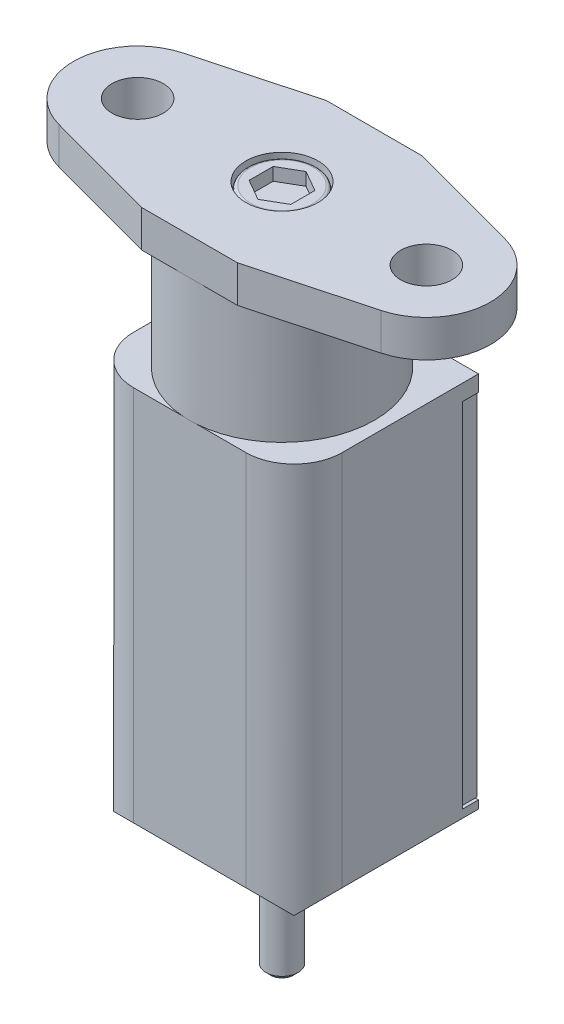
from build123d import *

# Parameters (mm, degrees)
SKETCH1_R                = 1.6
BOSS_EXTRUDE1_DEPTH      = 2.3
SKETCH2_R                = 5.765
BOSS_EXTRUDE2_DEPTH      = 7.7
SKETCH3_W                = 13
SKETCH3_H                = 26.5
BOSS_EXTRUDE3_DEPTH      = 5.75
BOSS_EXTRUDE3_DEPTH_BACK = 5.75
SKETCH4_W                = 1
SKETCH4_H                = 6
CHAMFER1_SIZE            = 3
FILLET1_R                = 3
CHAMFER2_SIZE            = 0.3
SKETCH9_R                = 2.25
CUT_EXTRUDE1_DEPTH       = 0.2
CUT_EXTRUDE2_DEPTH       = 1
SKETCH11_R               = 2.25
SKETCH11_R_2             = 2.15
CUT_EXTRUDE3_DEPTH       = 0.5
FILLET2_R                = 0.2
SKETCH12_R               = 0.3
CUT_EXTRUDE4_DEPTH       = 1
BOSS_EXTRUDE4_DEPTH      = 1


with BuildPart() as part:
    # Sketch1 → Boss-Extrude1 (new body)
    with BuildSketch(Plane(origin=(0, 0, 0), x_dir=(1, 0, 0), z_dir=(0, 1, 0))):
        with BuildLine():
            Line((3, 5.765), (-3, 5.765))
            Line((-3, 5.765), (-10.043565082, 3.861472766))
            ThreePointArc((-10.043565082, 3.861472766), (-13, 0), (-10.043565082, -3.861472766))
            Line((-10.043565082, -3.861472766), (-3, -5.765))
            Line((-3, -5.765), (3, -5.765))
            Line((3, -5.765), (10.043565082, -3.861472766))
            ThreePointArc((10.043565082, -3.861472766), (13, 0), (10.043565082, 3.861472766))
            Line((10.043565082, 3.861472766), (3, 5.765))
        make_face()
        with Locations((9, 0)):
            Circle(SKETCH1_R, mode=Mode.SUBTRACT)
        with Locations((-9, 0)):
            Circle(SKETCH1_R, mode=Mode.SUBTRACT)
    extrude(amount=-BOSS_EXTRUDE1_DEPTH)

    # Sketch2 → Boss-Extrude2 (add)
    with BuildSketch(Plane.XZ.offset(2.3)):
        Circle(SKETCH2_R)
    extrude(amount=BOSS_EXTRUDE2_DEPTH)

    # Sketch3 → Boss-Extrude3 (add, two sides)
    with BuildSketch(Plane.XY) as boss_extrude3_sk:
        with Locations((0, -23.25)):
            Rectangle(SKETCH3_W, SKETCH3_H)
    extrude(amount=BOSS_EXTRUDE3_DEPTH)
    extrude(boss_extrude3_sk.sketch, amount=-BOSS_EXTRUDE3_DEPTH_BACK)

    # Sketch4 → Revolve1 (revolve)
    with BuildSketch(Plane.XY):
        with Locations((0.5, -39.5)):
            Rectangle(SKETCH4_W, SKETCH4_H)
    revolve(axis=Axis((0, -36.5, 0), (0, -1, 0)))

    # Chamfer1
    chamfer1_edges = [part.edges().sort_by_distance(p)[0] for p in [
        (-6.5, -36.5, 0),
        (0, -36.5, -5.75),
        (6.5, -36.5, 0),
        (0, -36.5, 5.75),
    ]]
    chamfer(chamfer1_edges, length=CHAMFER1_SIZE)

    # Fillet1
    fillet1_edges = [part.edges().sort_by_distance(p)[0] for p in [
        (-6.5, -21.75, 5.75),
        (6.5, -21.75, 5.75),
    ]]
    fillet(fillet1_edges, radius=FILLET1_R)

    # Chamfer2
    chamfer2_edges = [part.edges().sort_by_distance(p)[0] for p in [
        (-1, -42.5, 0),
    ]]
    chamfer(chamfer2_edges, length=CHAMFER2_SIZE)

    # Sketch9 → Cut-Extrude1 (cut)
    with BuildSketch(Plane(origin=(0, 0, 0), x_dir=(1, 0, 0), z_dir=(0, 1, 0))):
        Circle(SKETCH9_R)
        Polygon((0, 1.5011107), (-1.3, 0.75055535), (-1.3, -0.75055535), (0, -1.5011107), (1.3, -0.75055535), (1.3, 0.75055535), align=None, mode=Mode.SUBTRACT)
    extrude(amount=-CUT_EXTRUDE1_DEPTH, mode=Mode.SUBTRACT)

    # Sketch10 → Cut-Extrude2 (cut)
    with BuildSketch(Plane(origin=(0, 0, 0), x_dir=(1, 0, 0), z_dir=(0, 1, 0))):
        Polygon((1.3, 0.75055535), (0, 1.5011107), (-1.3, 0.75055535), (-1.3, -0.75055535), (0, -1.5011107), (1.3, -0.75055535), align=None)
    extrude(amount=-CUT_EXTRUDE2_DEPTH, mode=Mode.SUBTRACT)

    # Sketch11 → Cut-Extrude3 (cut)
    with BuildSketch(Plane(origin=(0, -0.2, 0), x_dir=(1, 0, 0), z_dir=(0, 1, 0))):
        Circle(SKETCH11_R)
        Circle(SKETCH11_R_2, mode=Mode.SUBTRACT)
    extrude(amount=-CUT_EXTRUDE3_DEPTH, mode=Mode.SUBTRACT)

    # Fillet2
    fillet2_edges = [part.edges().sort_by_distance(p)[0] for p in [
        (-2.15, -0.2, 0),
    ]]
    fillet(fillet2_edges, radius=FILLET2_R)

    # Sketch12 → Cut-Extrude4 (cut)
    with BuildSketch(Plane(origin=(0, 0, -5.75), x_dir=(-1, 0, 0), z_dir=(0, 0, -1))):
        with Locations((0, -32.5)):
            Circle(SKETCH12_R)
        with BuildLine():
            Line((-6.5, -11), (6.5, -11))
            Line((6.5, -11), (6.5, -33))
            Line((6.5, -33), (1, -33))
            Line((1, -33), (1, -32.5))
            ThreePointArc((1, -32.5), (0, -31.5), (-1, -32.5))
            Line((-1, -32.5), (-1, -33))
            Line((-1, -33), (-6.5, -33))
            Line((-6.5, -33), (-6.5, -11))
        make_face()
    extrude(amount=-CUT_EXTRUDE4_DEPTH, mode=Mode.SUBTRACT)

    # Sketch13 → Boss-Extrude4 (add)
    with BuildSketch(Plane(origin=(0, 0, -4.75), x_dir=(-1, 0, 0), z_dir=(0, 0, -1))):
        with BuildLine():
            Line((6.4, -11.1), (-6.4, -11.1))
            Line((-6.4, -11.1), (-6.4, -32.9))
            Line((-6.4, -32.9), (-1.1, -32.9))
            Line((-1.1, -32.9), (-1.1, -32.5))
            ThreePointArc((-1.1, -32.5), (0, -31.4), (1.1, -32.5))
            Line((1.1, -32.5), (1.1, -32.9))
            Line((1.1, -32.9), (6.4, -32.9))
            Line((6.4, -32.9), (6.4, -11.1))
        make_face()
    extrude(amount=BOSS_EXTRUDE4_DEPTH)


solid = part.part
